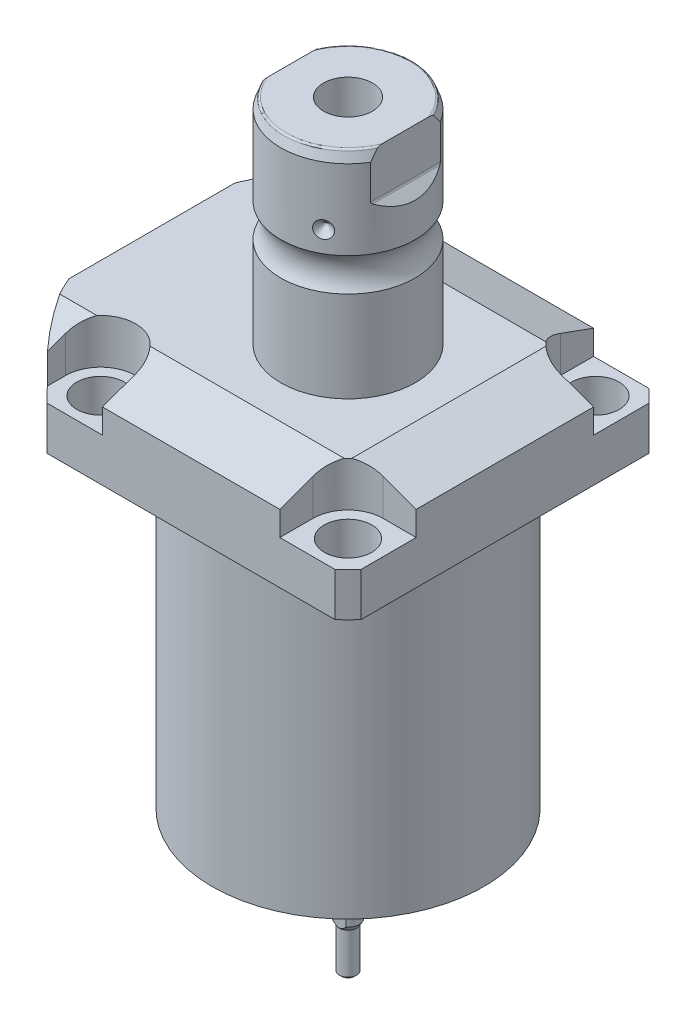
from build123d import *

# Parameters (mm, degrees)
SKETCH1_W               = 88.9
SKETCH1_H               = 100
EXTRUDE1_DEPTH          = 113.919
SKETCH2_OUTSIDE_W       = 137.146
SKETCH2_OUTSIDE_H       = 126.046
SKETCH2_OUTSIDE_R       = 60.325
CUT_EXTRUDE1_DEPTH      = 114.919
SKETCH3_W               = 38.1002
SKETCH3_H               = 88.9
FILLET1_R               = 0.381
CUT_EXTRUDE2_DEPTH      = 12.7
CUT_EXTRUDE9_START      = -56.55
CUT_EXTRUDE9_DEPTH      = 102
CUT_EXTRUDE7_DEPTH      = 45.45
CUT_EXTRUDE7_DEPTH_BACK = 45.45
SKETCH10_R              = 1.1811
SKETCH11_R              = 1.1811
LPATTERN1_COUNT         = 2
LPATTERN1_PITCH         = 25.9588
CUT_EXTRUDE8_DEPTH      = 53.34
SKETCH17_W              = 6.7435
SKETCH17_H              = 12.319
HOLE1_AT_2_COUNT        = 2
HOLE1_AT_2_PITCH        = 70.104
HOLE1_AT_3_COUNT        = 2
HOLE1_AT_3_PITCH        = 99.142027577
HOLE1_AT_4_COUNT        = 2
HOLE1_AT_4_PITCH        = 70.104
CHAMFER1_SIZE           = 0.635
FILLET2_R               = 0.635
CIRPATTERN1_COUNT       = 3
CUT_EXTRUDE10_DEPTH     = 3.81000762
SKETCH25_W              = 2.70510541
SKETCH25_H              = 1.320802642
SKETCH26_R              = 1.27000254
CUT_EXTRUDE11_DEPTH     = 7.62001524


with BuildPart() as part:
    # Sketch1 → Extrude1 (new body)
    with BuildSketch(Plane.ZX):
        with Locations((0, -5.55)):
            Rectangle(SKETCH1_W, SKETCH1_H)
    extrude(amount=EXTRUDE1_DEPTH)

    # Sketch2 outside → Cut-Extrude1 (cut, through all)
    with BuildSketch(Plane.XZ):
        with Locations((-5.55, 0)):
            Rectangle(SKETCH2_OUTSIDE_W, SKETCH2_OUTSIDE_H)
        Circle(SKETCH2_OUTSIDE_R, mode=Mode.SUBTRACT)
    extrude(amount=-CUT_EXTRUDE1_DEPTH, mode=Mode.SUBTRACT)

    # Sketch3 → Cut-Revolve1 (revolve, cut)
    with BuildSketch(Plane(origin=(0, 0, 0), x_dir=(0, 0, 1), z_dir=(1, 0, 0))):
        with Locations((57.5436, -44.45)):
            Rectangle(SKETCH3_W, SKETCH3_H)
    revolve(axis=Axis((0, 93.345, 0), (0, -1, 0)), mode=Mode.SUBTRACT)

    # Fillet1
    fillet1_edges = [part.edges().sort_by_distance(p)[0] for p in [
        (0, 88.9, -38.4935),
    ]]
    fillet(fillet1_edges, radius=FILLET1_R)

    # Sketch4 → Cut-Extrude2 (cut)
    with BuildSketch(Plane(origin=(0, 113.919, 0), x_dir=(-1, 0, 0), z_dir=(0, 1, 0))):
        with BuildLine():
            Line((-25.121, -44.45), (-25.121, -35.052))
            ThreePointArc((-25.121, -35.052), (-28.029722556, -28.029722556), (-35.052, -25.121))
            Line((-35.052, -25.121), (-44.45, -25.121))
            Line((-44.45, -25.121), (-44.45, -44.45))
            Line((-44.45, -44.45), (-25.121, -44.45))
        make_face()
        with BuildLine():
            Line((44.983, -44.45), (25.121, -44.45))
            Line((25.121, -44.45), (25.121, -35.052))
            ThreePointArc((25.121, -35.052), (35.052, -25.121), (44.983, -35.052))
            Line((44.983, -35.052), (44.983, -44.45))
        make_face()
        with BuildLine():
            Line((25.121, 44.45), (25.121, 35.052))
            ThreePointArc((25.121, 35.052), (35.052, 25.121), (44.983, 35.052))
            Line((44.983, 35.052), (44.983, 44.45))
            Line((44.983, 44.45), (25.121, 44.45))
        make_face()
        with BuildLine():
            Line((-35.052, 25.121), (-44.45, 25.121))
            Line((-44.45, 25.121), (-44.45, 44.45))
            Line((-44.45, 44.45), (-25.121, 44.45))
            Line((-25.121, 44.45), (-25.121, 35.052))
            ThreePointArc((-25.121, 35.052), (-28.029722556, 28.029722556), (-35.052, 25.121))
        make_face()
    extrude(amount=-CUT_EXTRUDE2_DEPTH, mode=Mode.SUBTRACT)

    # Sketch5 → Cut-Extrude9 (cut)
    with BuildSketch(Plane(origin=(0, 0, 0), x_dir=(0, 0, -1), z_dir=(1, 0, 0)).offset(CUT_EXTRUDE9_START)):
        Polygon((-28.575, 113.919), (-44.45, 108.140972531), (-44.45, 113.919), align=None)
    cut_extrude9 = extrude(amount=CUT_EXTRUDE9_DEPTH, mode=Mode.SUBTRACT)

    # Mirror1: Cut-Extrude9 across plane
    add(cut_extrude9.mirror(Plane.XY), mode=Mode.SUBTRACT)

    # Sketch9 → Cut-Extrude7 (cut, two sides)
    with BuildSketch(Plane.XY) as cut_extrude7_sk:
        Polygon((28.575, 113.919), (44.45, 108.140972531), (44.45, 113.919), align=None)
    extrude(amount=CUT_EXTRUDE7_DEPTH, mode=Mode.SUBTRACT)
    extrude(cut_extrude7_sk.sketch, amount=-CUT_EXTRUDE7_DEPTH_BACK, mode=Mode.SUBTRACT)

    # Sketch20 → Cut-Revolve4 (revolve, cut)
    with BuildSketch(Plane(origin=(-41.402, 88.9, -18.1102), x_dir=(0, 1, 0), z_dir=(1, 0, 0)), mode=Mode.PRIVATE) as cut_revolve4_sk:
        Polygon((0, 41.9225), (1.4478, 41.9225), (1.4478, 39.4714), (2.4638, 39.4714), (2.4638, 37.4648), (13.4366, 37.4648), (13.4366, 36.2202), (0, 36.2202), align=None)
    cut_revolve4 = revolve(cut_revolve4_sk.sketch.rotate(Axis((-41.402, 81.620304954, 18.11), (0, 1, 0)), 180), axis=Axis((-41.402, 81.620304954, 18.11), (0, 1, 0)), mode=Mode.SUBTRACT)  # turned: the seam where the file's is

    # Mirror10: Cut-Revolve4 across plane
    add(cut_revolve4.mirror(Plane.XY), mode=Mode.SUBTRACT)

    # S2D0007 → Cut-Revolve2 (revolve, cut)
    with BuildSketch(Plane(origin=(-55.5498, 101.9048, 12.9794), x_dir=(0, 1, 0), z_dir=(0, 0, 1)), mode=Mode.PRIVATE) as cut_revolve2_sk:
        Polygon((0.0002, 0.0002), (10.7444, 0.0002), (10.7444, -0.2538), (6.655, -0.2538), (5.9438, -0.965), (5.9438, -14.427), (0.0002, -14.427), align=None)
    cut_revolve2 = revolve(cut_revolve2_sk.sketch.rotate(Axis((-40.6146, 101.905, 12.9794), (-1, 0, 0)), 90), axis=Axis((-40.6146, 101.905, 12.9794), (-1, 0, 0)), mode=Mode.SUBTRACT)  # turned: the seam where the file's is

    # LPattern1: Cut-Revolve2 ×2
    with Locations(*[(0, 0, -i * LPATTERN1_PITCH) for i in range(1, LPATTERN1_COUNT)]):
        add(cut_revolve2, mode=Mode.SUBTRACT)

    # Sketch15 → Revolve3 (revolve)
    with BuildSketch(Plane(origin=(0, 0, 0), x_dir=(0, -1, 0), z_dir=(1, 0, 0)), mode=Mode.PRIVATE) as revolve3_sk:
        with BuildLine():
            Line((-113.919, 0), (-113.919, 19.05))
            Line((-113.919, 19.05), (-139.640705156, 19.05))
            ThreePointArc((-139.640705156, 19.05), (-144.348, 17.5005), (-149.055294844, 19.05))
            Line((-149.055294844, 19.05), (-171.602, 19.05))
            Line((-171.602, 19.05), (-174.523, 17.986842946))
            Line((-174.523, 17.986842946), (-174.523, 0))
            Line((-174.523, 0), (-113.919, 0))
        make_face()
    revolve(revolve3_sk.sketch.rotate(Axis((0, 197.63613, 0), (0, -1, 0)), 180), axis=Axis((0, 197.63613, 0), (0, -1, 0)))  # turned: the seam where the file's is

    # Sketch16 → Cut-Extrude8 (cut, symmetric)
    with BuildSketch(Plane(origin=(0, 0, 0), x_dir=(0, -1, 0), z_dir=(0, 0, 1))):
        with BuildLine():
            Line((-174.523, 19.05), (-158.738869265, 19.05))
            Line((-158.738869265, 19.05), (-161.284184633, 16.504684633))
            ThreePointArc((-161.284184633, 16.504684633), (-161.531395225, 16.339503796), (-161.823, 16.2815))
            Line((-161.823, 16.2815), (-174.523, 16.2815))
            Line((-174.523, 16.2815), (-174.523, 19.05))
        make_face()
        with BuildLine():
            Line((-174.523, -19.05), (-174.523, -16.2815))
            Line((-174.523, -16.2815), (-161.823, -16.2815))
            ThreePointArc((-161.823, -16.2815), (-161.531395225, -16.339503796), (-161.284184633, -16.504684633))
            Line((-161.284184633, -16.504684633), (-158.738869265, -19.05))
            Line((-158.738869265, -19.05), (-174.523, -19.05))
        make_face()
    extrude(amount=CUT_EXTRUDE8_DEPTH, both=True, mode=Mode.SUBTRACT)

    # Sketch17 → Hole1 (revolve, cut)
    with BuildSketch(Plane(origin=(35.052, 101.219, -35.052), x_dir=(0, 0, 1), z_dir=(1, 0, 0))):
        with Locations((3.37175, 6.1595)):
            Rectangle(SKETCH17_W, SKETCH17_H)
    hole1 = revolve(axis=Axis((35.052, -8.781, -35.052), (0, 1, 0)), mode=Mode.SUBTRACT)

    # Hole1 at 2: Hole1 ×2
    with Locations(*[(0, 0, i * HOLE1_AT_2_PITCH) for i in range(1, HOLE1_AT_2_COUNT)]):
        add(hole1, mode=Mode.SUBTRACT)

    # Hole1 at 3: Hole1 ×2
    with Locations(*[Vector(-0.707106781, 0, 0.707106781) * (i * HOLE1_AT_3_PITCH) for i in range(1, HOLE1_AT_3_COUNT)]):
        add(hole1, mode=Mode.SUBTRACT)

    # Hole1 at 4: Hole1 ×2
    with Locations(*[(-i * HOLE1_AT_4_PITCH, 0, 0) for i in range(1, HOLE1_AT_4_COUNT)]):
        add(hole1, mode=Mode.SUBTRACT)

    # Chamfer1
    chamfer1_edges = [part.edges().sort_by_distance(p)[0] for p in [
        (-41.402, 91.3638, 19.3546),
        (-41.402, 91.3638, -19.3546),
    ]]
    chamfer(chamfer1_edges, length=CHAMFER1_SIZE)

    # Sketch21 → Cut-Revolve5 (revolve, cut)
    with BuildSketch(Plane.XY, mode=Mode.PRIVATE) as cut_revolve5_sk:
        Polygon((0, 144.956512296), (6.9342, 149.123), (6.9342, 174.523), (0, 174.523), align=None)
    revolve(cut_revolve5_sk.sketch.rotate(Axis((0, 0, 0), (0, 1, 0)), 270), axis=Axis((0, 0, 0), (0, 1, 0)), mode=Mode.SUBTRACT)  # turned: the seam where the file's is

    # Fillet2
    fillet2_edges = [part.edges().sort_by_distance(p)[0] for p in [
        (0, 174.523, -17.986842946),
        (0, 174.523, 17.986842946),
    ]]
    fillet(fillet2_edges, radius=FILLET2_R)

    # Sketch22 → Cut-Revolve6 (revolve, cut)
    with BuildSketch(Plane.XY, mode=Mode.PRIVATE) as cut_revolve6_sk:
        Polygon((-19.05, 157.429), (-16.637, 155.016), (-19.05, 155.016), align=None)
    cut_revolve6 = revolve(cut_revolve6_sk.sketch.rotate(Axis((-37.997376206, 155.016, 0), (1, 0, 0)), 90), axis=Axis((-37.997376206, 155.016, 0), (1, 0, 0)), mode=Mode.SUBTRACT)  # turned: the seam where the file's is

    # CirPattern1: Cut-Revolve6 ×3 about axis
    cirpattern1_axis = Axis((0, 197.63613, 0), (0, 1, 0))
    for i in range(1, CIRPATTERN1_COUNT):
        add(cut_revolve6.rotate(cirpattern1_axis, i * 360 / CIRPATTERN1_COUNT), mode=Mode.SUBTRACT)

    # Sketch23 → Revolve5 (revolve)
    with BuildSketch(Plane(origin=(0, 0, 0), x_dir=(0, 0, -1), z_dir=(1, 0, 0)), mode=Mode.PRIVATE) as revolve5_sk:
        Polygon((0, 0), (3.17500635, 0), (3.17500635, -26.953076991), (2.438404877, -28.228908167), (2.438404877, -39.75182855), (1.803403607, -40.38682982), (0, -40.38682982), align=None)
    revolve(revolve5_sk.sketch.rotate(Axis((0, -1000, 0), (0, 1, 0)), 180), axis=Axis((0, -1000, 0), (0, 1, 0)))  # turned: the seam where the file's is

    # Sketch24 → Cut-Extrude10 (cut, symmetric)
    with BuildSketch(Plane(origin=(0, 0, 0), x_dir=(0, 0, -1), z_dir=(1, 0, 0))):
        Polygon((3.17500635, -23.838696723), (2.501905004, -24.51179807), (2.501905004, -40.38682982), (3.17500635, -40.38682982), align=None)
        Polygon((-3.17500635, -40.38682982), (-2.501905004, -40.38682982), (-2.501905004, -24.51179807), (-3.17500635, -23.838696723), align=None)
    extrude(amount=CUT_EXTRUDE10_DEPTH, both=True, mode=Mode.SUBTRACT)

    # Sketch25 → Cut-Revolve7 (revolve, cut)
    with BuildSketch(Plane(origin=(0, 0, 0), x_dir=(0, 0, -1), z_dir=(1, 0, 0)), mode=Mode.PRIVATE) as cut_revolve7_sk:
        with Locations((12.998475997, 0.660401321)):
            Rectangle(SKETCH25_W, SKETCH25_H)
    revolve(cut_revolve7_sk.sketch.rotate(Axis((0, -1000, 0), (0, 1, 0)), 218.00100076), axis=Axis((0, -1000, 0), (0, 1, 0)), mode=Mode.SUBTRACT)  # turned: the seam where the file's is

    # Sketch26 → Cut-Extrude11 (cut)
    with BuildSketch(Plane.XZ):
        with Locations(Location((19.431038862, 0, 0), (0, 0, 270))):  # turned: the seam where the file's is
            Circle(SKETCH26_R)
        with Locations(Location((18.768942269, -5.029122924, 0), (0, 0, 270))):  # turned: the seam where the file's is
            Circle(SKETCH26_R)
        with Locations(Location((-13.739819345, 13.739819345, 0), (0, 0, 90))):  # turned: the seam where the file's is
            Circle(SKETCH26_R)
        with Locations(Location((-9.715519431, 16.827773276, 0), (0, 0, 90))):  # turned: the seam where the file's is
            Circle(SKETCH26_R)
        with Locations(Location((-13.739819345, -13.739819345, 0), (0, 0, 270))):  # turned: the seam where the file's is
            Circle(SKETCH26_R)
        with Locations(Location((-9.715519431, -16.827773276, 0), (0, 0, 270))):  # turned: the seam where the file's is
            Circle(SKETCH26_R)
    extrude(amount=-CUT_EXTRUDE11_DEPTH, mode=Mode.SUBTRACT)


with BuildPart() as body_2:
    # Sketch10 → Revolve4 (revolve)
    with BuildSketch(Plane(origin=(-41.402, 88.9, -18.1102), x_dir=(0, 1, 0), z_dir=(1, 0, 0))):
        with Locations((0.2667, 4.5214)):
            Circle(SKETCH10_R)
    revolve(axis=Axis((-41.402, 87.86749, -18.11), (0, 1, 0)))


with BuildPart() as body_3:
    # Sketch11 → Revolve2 (revolve)
    with BuildSketch(Plane(origin=(-41.402, 88.9, 18.1102), x_dir=(0, 1, 0), z_dir=(1, 0, 0)), mode=Mode.PRIVATE) as revolve2_sk:
        with Locations((0.2667, 4.521)):
            Circle(SKETCH11_R)
    revolve(revolve2_sk.sketch.rotate(Axis((-41.402, 87.86749, 18.11), (0, 1, 0)), 180), axis=Axis((-41.402, 87.86749, 18.11), (0, 1, 0)))  # turned: the seam where the file's is


solid = Compound([part.part, body_2.part, body_3.part])
